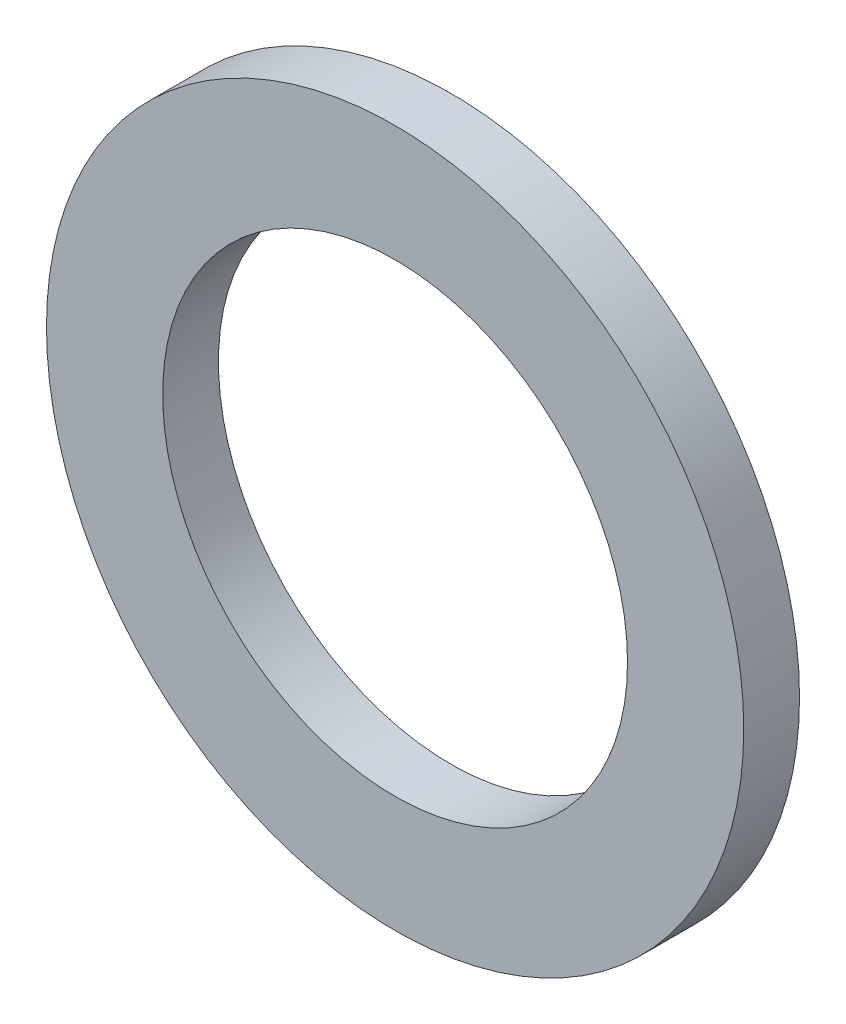
from build123d import *

# Parameters (mm, degrees)
SKETCH1_R           = 4.7625
SKETCH1_R_2         = 3.175
BOSS_EXTRUDE1_DEPTH = 0.762


with BuildPart() as part:
    # Sketch1 → Boss-Extrude1 (new body)
    with BuildSketch(Plane.XY):
        Circle(SKETCH1_R)
        Circle(SKETCH1_R_2, mode=Mode.SUBTRACT)
    extrude(amount=BOSS_EXTRUDE1_DEPTH)


solid = part.part
